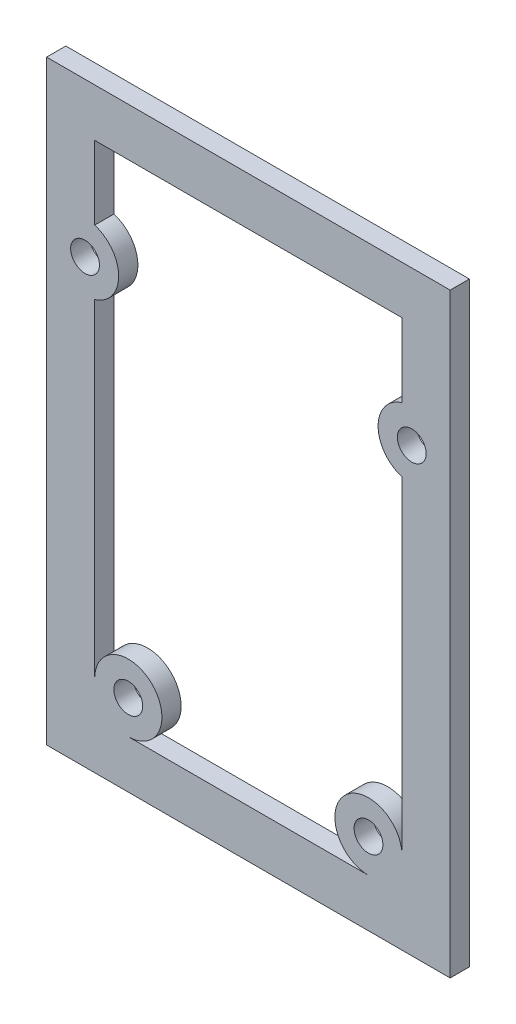
from build123d import *

# Parameters (mm, degrees)
SKETCH1_R           = 3.5
SKETCH1_R_2         = 1.5
BOSS_EXTRUDE1_DEPTH = 2


with BuildPart() as part:
    # Sketch1 → Boss-Extrude1 (new body)
    with BuildSketch(Plane.XY):
        with BuildLine():
            ThreePointArc((-73.101516296, -83), (-75.576390016, -81.974873749), (-76.601516296, -79.500000041))
            Line((-76.601516296, -79.500000041), (-76.601516296, -83))
            Line((-76.601516296, -83), (-73.101516296, -83))
        make_face()
        with Locations((-73.101516296, -79.5)):
            Circle(SKETCH1_R)
        with Locations((-73.101516296, -79.5)):
            Circle(SKETCH1_R_2, mode=Mode.SUBTRACT)
        with BuildLine():
            Line((-44.601516296, -83), (-44.601516296, -79.5))
            ThreePointArc((-44.601516296, -79.5), (-45.626642562, -81.974873734), (-48.101516296, -83))
            Line((-48.101516296, -83), (-44.601516296, -83))
        make_face()
        with Locations((-48.101516296, -79.5)):
            Circle(SKETCH1_R)
        with Locations((-48.101516296, -79.5)):
            Circle(SKETCH1_R_2, mode=Mode.SUBTRACT)
        with BuildLine():
            ThreePointArc((-76.601516296, -50.477288358), (-79.44300278, -53.809155179), (-81.601516296, -57.61916848))
            Line((-81.601516296, -57.61916848), (-81.601516296, -76.38083152))
            ThreePointArc((-81.601516296, -76.38083152), (-76.864972263, -83.263455967), (-69.982347816, -88))
            Line((-69.982347816, -88), (-51.220684776, -88))
            ThreePointArc((-51.220684776, -88), (-44.338060329, -83.263455967), (-39.601516296, -76.38083152))
            Line((-39.601516296, -76.38083152), (-39.601516296, -57.61916848))
            ThreePointArc((-39.601516296, -57.61916848), (-41.760029812, -53.809155179), (-44.601516296, -50.477288358))
            Line((-44.601516296, -50.477288358), (-44.601516296, -79.5))
            Line((-44.601516296, -79.5), (-44.601516296, -83))
            Line((-44.601516296, -83), (-48.101516296, -83))
            Line((-48.101516296, -83), (-73.101516296, -83))
            Line((-73.101516296, -83), (-76.601516296, -83))
            Line((-76.601516296, -83), (-76.601516296, -79.500000041))
            Line((-76.601516296, -79.500000041), (-76.601516296, -50.477288358))
        make_face()
        with BuildLine():
            ThreePointArc((-69.982347816, -88), (-76.864972263, -83.263455967), (-81.601516296, -76.38083152))
            Line((-81.601516296, -76.38083152), (-81.601516296, -88))
            Line((-81.601516296, -88), (-69.982347816, -88))
        make_face()
        with BuildLine():
            Line((-39.601516296, -88), (-39.601516296, -76.38083152))
            ThreePointArc((-39.601516296, -76.38083152), (-44.338060329, -83.263455967), (-51.220684776, -88))
            Line((-51.220684776, -88), (-39.601516296, -88))
        make_face()
        with BuildLine():
            Line((-39.601516296, -26), (-81.601516296, -26))
            Line((-81.601516296, -26), (-81.601516296, -57.61916848))
            ThreePointArc((-81.601516296, -57.61916848), (-79.44300278, -53.809155179), (-76.601516296, -50.477288358))
            Line((-76.601516296, -50.477288358), (-76.601516296, -45.354101966))
            ThreePointArc((-76.601516296, -45.354101966), (-74.101516296, -42), (-76.601516296, -38.645898034))
            Line((-76.601516296, -38.645898034), (-76.601516296, -31))
            Line((-76.601516296, -31), (-44.601516296, -31))
            Line((-44.601516296, -31), (-44.601516296, -38.645898034))
            ThreePointArc((-44.601516296, -38.645898034), (-47.101516296, -42), (-44.601516296, -45.354101966))
            Line((-44.601516296, -45.354101966), (-44.601516296, -50.477288358))
            ThreePointArc((-44.601516296, -50.477288358), (-41.760029812, -53.809155179), (-39.601516296, -57.61916848))
            Line((-39.601516296, -57.61916848), (-39.601516296, -26))
        make_face()
        with Locations((-77.601516296, -42)):
            Circle(SKETCH1_R_2, mode=Mode.SUBTRACT)
        with Locations((-43.601516296, -42)):
            Circle(SKETCH1_R_2, mode=Mode.SUBTRACT)
    extrude(amount=BOSS_EXTRUDE1_DEPTH)


solid = part.part
